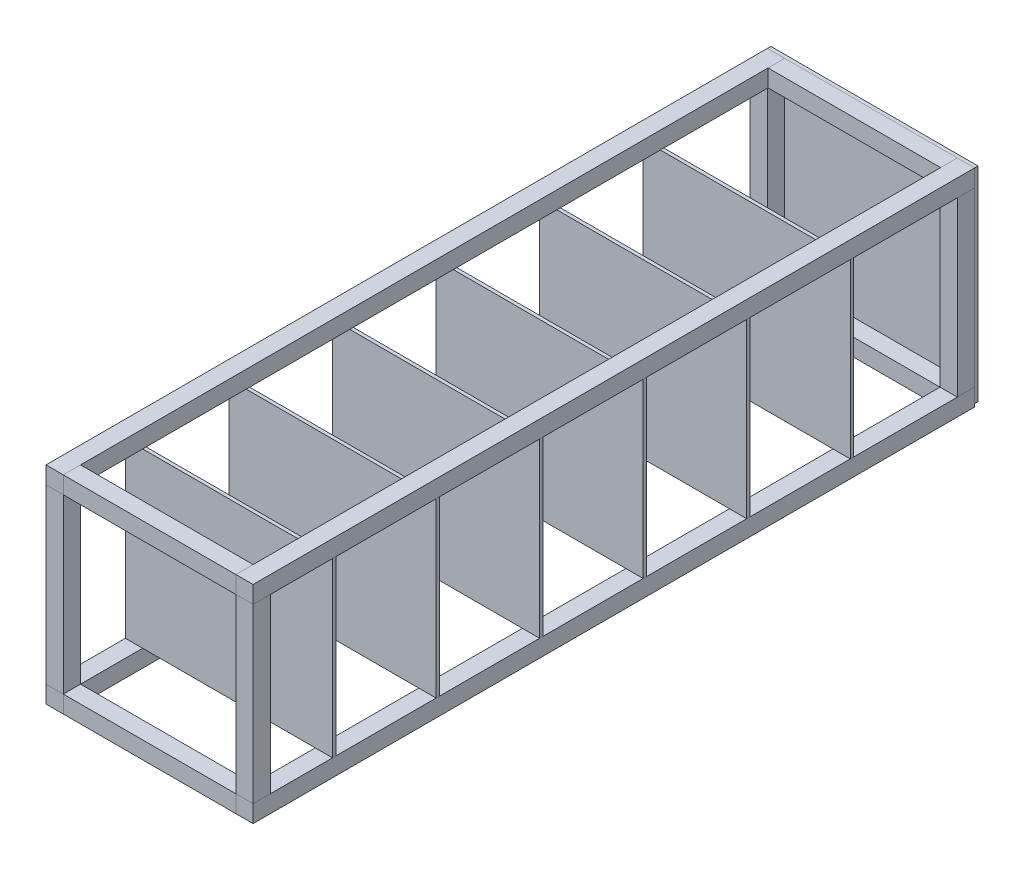
from build123d import *

# Parameters (mm, degrees)
SKETCH1_W             = 50
SKETCH1_H             = 50
BOSS_EXTRUDE1_DEPTH   = 2090
BOSS_EXTRUDE1_2_DEPTH = 2090
BOSS_EXTRUDE1_3_DEPTH = 2090
BOSS_EXTRUDE1_4_DEPTH = 2090
SKETCH2_W             = 50
SKETCH2_H             = 50
BOSS_EXTRUDE2_DEPTH   = 500
BOSS_EXTRUDE2_2_DEPTH = 500
BOSS_EXTRUDE2_3_DEPTH = 500
BOSS_EXTRUDE2_4_DEPTH = 500
SKETCH3_W             = 50
SKETCH3_H             = 50
BOSS_EXTRUDE3_DEPTH   = 500
BOSS_EXTRUDE3_2_DEPTH = 500
SKETCH3_W_2           = 48.270716069
BOSS_EXTRUDE3_3_DEPTH = 500
BOSS_EXTRUDE3_4_DEPTH = 500
SKETCH5_W             = 10
SKETCH5_H             = 500
BOSS_EXTRUDE4_DEPTH   = 600
BOSS_EXTRUDE4_2_DEPTH = 600
BOSS_EXTRUDE4_3_DEPTH = 600
BOSS_EXTRUDE4_4_DEPTH = 600
BOSS_EXTRUDE4_5_DEPTH = 600
BOSS_EXTRUDE4_6_DEPTH = 600
SKETCH6_W             = 600
SKETCH6_H             = 591.274599244
BOSS_EXTRUDE5_DEPTH   = 10


with BuildPart() as part:
    # Sketch1 → Boss-Extrude1 (new body)
    with BuildSketch(Plane.XY):
        with Locations((-575, 525)):
            Rectangle(SKETCH1_W, SKETCH1_H)
    extrude(amount=BOSS_EXTRUDE1_DEPTH)


with BuildPart() as body_2:
    # Sketch1 → Boss-Extrude1 2 (new body)
    with BuildSketch(Plane.XY):
        with Locations((-25, -25)):
            Rectangle(SKETCH1_W, SKETCH1_H)
    extrude(amount=BOSS_EXTRUDE1_2_DEPTH)


with BuildPart() as body_3:
    # Sketch1 → Boss-Extrude1 3 (new body)
    with BuildSketch(Plane.XY):
        with Locations((-575, -25)):
            Rectangle(SKETCH1_W, SKETCH1_H)
    extrude(amount=BOSS_EXTRUDE1_3_DEPTH)


with BuildPart() as body_4:
    # Sketch1 → Boss-Extrude1 4 (new body)
    with BuildSketch(Plane.XY):
        with Locations((-25, 525)):
            Rectangle(SKETCH1_W, SKETCH1_H)
    extrude(amount=BOSS_EXTRUDE1_4_DEPTH)


with BuildPart() as body_5:
    # Sketch2 → Boss-Extrude2 (new body)
    with BuildSketch(Plane(origin=(0, 0, 0), x_dir=(1, 0, 0), z_dir=(0, 1, 0))):
        with Locations((-575, -25)):
            Rectangle(SKETCH2_W, SKETCH2_H)
    extrude(amount=BOSS_EXTRUDE2_DEPTH)


with BuildPart() as body_6:
    # Sketch2 → Boss-Extrude2 2 (new body)
    with BuildSketch(Plane(origin=(0, 0, 0), x_dir=(1, 0, 0), z_dir=(0, 1, 0))):
        with Locations((-25, -25)):
            Rectangle(SKETCH2_W, SKETCH2_H)
    extrude(amount=BOSS_EXTRUDE2_2_DEPTH)


with BuildPart() as body_7:
    # Sketch2 → Boss-Extrude2 3 (new body)
    with BuildSketch(Plane(origin=(0, 0, 0), x_dir=(1, 0, 0), z_dir=(0, 1, 0))):
        with Locations((-575, -2065)):
            Rectangle(SKETCH2_W, SKETCH2_H)
    extrude(amount=BOSS_EXTRUDE2_3_DEPTH)


with BuildPart() as body_8:
    # Sketch2 → Boss-Extrude2 4 (new body)
    with BuildSketch(Plane(origin=(0, 0, 0), x_dir=(1, 0, 0), z_dir=(0, 1, 0))):
        with Locations((-25, -2065)):
            Rectangle(SKETCH2_W, SKETCH2_H)
    extrude(amount=BOSS_EXTRUDE2_4_DEPTH)


with BuildPart() as body_9:
    # Sketch3 → Boss-Extrude3 (new body)
    with BuildSketch(Plane(origin=(-550, 0, 0), x_dir=(0, 0, -1), z_dir=(1, 0, 0))):
        with Locations((-2065, 525)):
            Rectangle(SKETCH3_W, SKETCH3_H)
    extrude(amount=BOSS_EXTRUDE3_DEPTH)


with BuildPart() as body_10:
    # Sketch3 → Boss-Extrude3 2 (new body)
    with BuildSketch(Plane(origin=(-550, 0, 0), x_dir=(0, 0, -1), z_dir=(1, 0, 0))):
        with Locations((-2065, -25)):
            Rectangle(SKETCH3_W, SKETCH3_H)
    extrude(amount=BOSS_EXTRUDE3_2_DEPTH)


with BuildPart() as body_11:
    # Sketch3 → Boss-Extrude3 3 (new body)
    with BuildSketch(Plane(origin=(-550, 0, 0), x_dir=(0, 0, -1), z_dir=(1, 0, 0))):
        with Locations((-24.135358035, 525)):
            Rectangle(SKETCH3_W_2, SKETCH3_H)
    extrude(amount=BOSS_EXTRUDE3_3_DEPTH)


with BuildPart() as body_12:
    # Sketch3 → Boss-Extrude3 4 (new body)
    with BuildSketch(Plane(origin=(-550, 0, 0), x_dir=(0, 0, -1), z_dir=(1, 0, 0))):
        with Locations((-25, -25)):
            Rectangle(SKETCH3_W, SKETCH3_H)
    extrude(amount=BOSS_EXTRUDE3_4_DEPTH)


with BuildPart() as body_13:
    # Sketch5 → Boss-Extrude4 (new body)
    with BuildSketch(Plane.ZY.offset(600)):
        with Locations((355, 250)):
            Rectangle(SKETCH5_W, SKETCH5_H)
    extrude(amount=-BOSS_EXTRUDE4_DEPTH)


with BuildPart() as body_14:
    # Sketch5 → Boss-Extrude4 2 (new body)
    with BuildSketch(Plane.ZY.offset(600)):
        with Locations((655, 250)):
            Rectangle(SKETCH5_W, SKETCH5_H)
    extrude(amount=-BOSS_EXTRUDE4_2_DEPTH)


with BuildPart() as body_15:
    # Sketch5 → Boss-Extrude4 3 (new body)
    with BuildSketch(Plane.ZY.offset(600)):
        with Locations((955, 250)):
            Rectangle(SKETCH5_W, SKETCH5_H)
    extrude(amount=-BOSS_EXTRUDE4_3_DEPTH)


with BuildPart() as body_16:
    # Sketch5 → Boss-Extrude4 4 (new body)
    with BuildSketch(Plane.ZY.offset(600)):
        with Locations((1255, 250)):
            Rectangle(SKETCH5_W, SKETCH5_H)
    extrude(amount=-BOSS_EXTRUDE4_4_DEPTH)


with BuildPart() as body_17:
    # Sketch5 → Boss-Extrude4 5 (new body)
    with BuildSketch(Plane.ZY.offset(600)):
        with Locations((1555, 250)):
            Rectangle(SKETCH5_W, SKETCH5_H)
    extrude(amount=-BOSS_EXTRUDE4_5_DEPTH)


with BuildPart() as body_18:
    # Sketch5 → Boss-Extrude4 6 (new body)
    with BuildSketch(Plane.ZY.offset(600)):
        with Locations((1855, 250)):
            Rectangle(SKETCH5_W, SKETCH5_H)
    extrude(amount=-BOSS_EXTRUDE4_6_DEPTH)


with BuildPart() as body_19:
    # Sketch6 → Boss-Extrude5 (new body)
    with BuildSketch(Plane(origin=(0, 0, 0), x_dir=(-1, 0, 0), z_dir=(0, 0, -1))):
        with Locations((300, 254.362700378)):
            Rectangle(SKETCH6_W, SKETCH6_H)
    extrude(amount=BOSS_EXTRUDE5_DEPTH)


solid = Compound([part.part, body_2.part, body_3.part, body_4.part, body_5.part, body_6.part, body_7.part, body_8.part, body_9.part, body_10.part, body_11.part, body_12.part, body_13.part, body_14.part, body_15.part, body_16.part, body_17.part, body_18.part, body_19.part])
